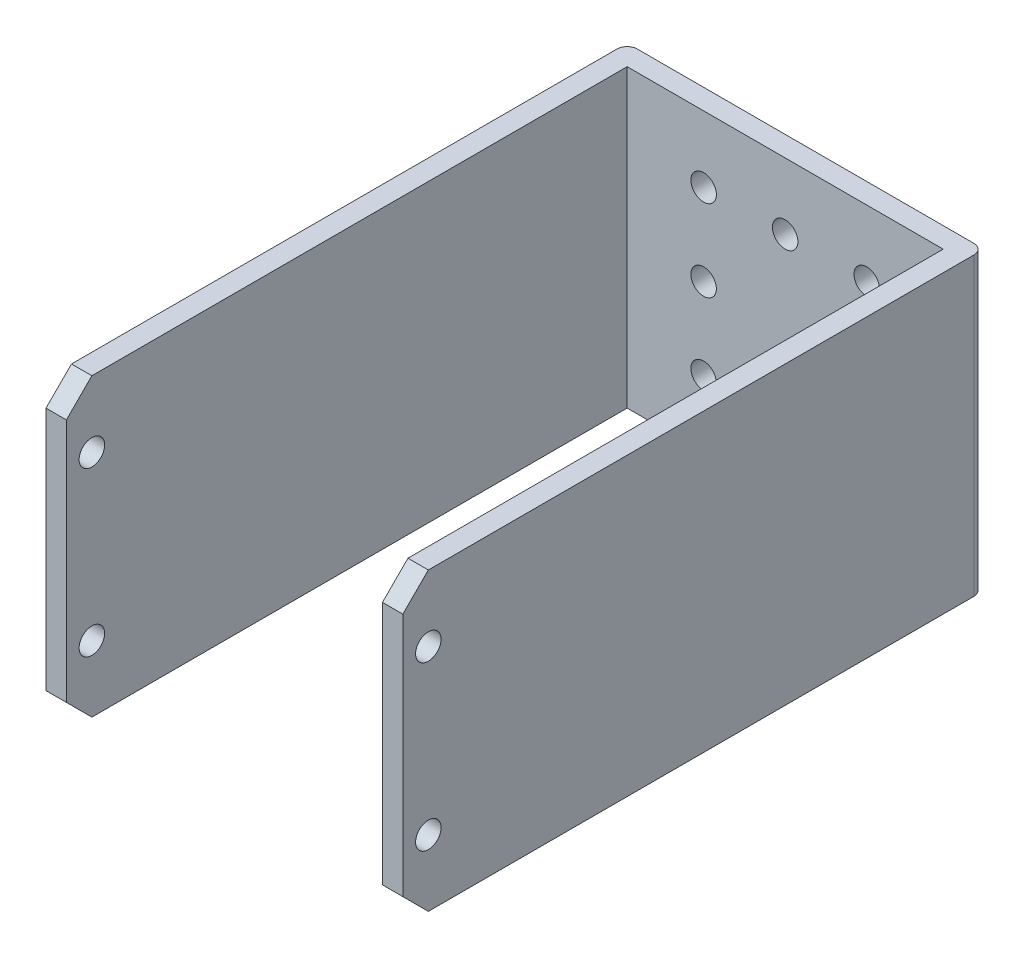
from build123d import *

# Parameters (mm, degrees)
SKETCH1_W           = 35
SKETCH1_H           = 29
BOSS_EXTRUDE1_DEPTH = 57
SKETCH3_W           = 31
SKETCH3_H           = 29
CUT_EXTRUDE1_DEPTH  = 55
FILLET1_R           = 1
CHAMFER1_SIZE       = 2.5
SKETCH4_R           = 1.25
CUT_EXTRUDE2_DEPTH  = 40.5
SKETCH7_R           = 1.25
CUT_EXTRUDE3_DEPTH  = 5


with BuildPart() as part:
    # Sketch1 → Boss-Extrude1 (new body)
    with BuildSketch(Plane.XY):
        with Locations((17.5, 14.5)):
            Rectangle(SKETCH1_W, SKETCH1_H)
    extrude(amount=BOSS_EXTRUDE1_DEPTH)

    # Sketch3 → Cut-Extrude1 (cut)
    with BuildSketch(Plane.XY.offset(57)):
        with Locations((17.5, 14.5)):
            Rectangle(SKETCH3_W, SKETCH3_H)
    extrude(amount=-CUT_EXTRUDE1_DEPTH, mode=Mode.SUBTRACT)

    # Fillet1
    fillet1_edges = [part.edges().sort_by_distance(p)[0] for p in [
        (0, 14.5, 0),
        (35, 14.5, 0),
    ]]
    fillet(fillet1_edges, radius=FILLET1_R)

    # Chamfer1
    chamfer1_edges = [part.edges().sort_by_distance(p)[0] for p in [
        (1, 0, 57),
        (1, 29, 57),
        (34, 0, 57),
        (34, 29, 57),
    ]]
    chamfer(chamfer1_edges, length=CHAMFER1_SIZE)

    # Sketch4 → Cut-Extrude2 (cut)
    with BuildSketch(Plane.ZY):
        with Locations((54.5, 22.5)):
            Circle(SKETCH4_R)
        with Locations((54.5, 6.5)):
            Circle(SKETCH4_R)
    extrude(amount=-CUT_EXTRUDE2_DEPTH, mode=Mode.SUBTRACT)

    # Sketch7 → Cut-Extrude3 (cut)
    with BuildSketch(Plane.XY.offset(2)):
        with Locations((9.5, 6.5)):
            Circle(SKETCH7_R)
        with Locations((17.5, 6.5)):
            Circle(SKETCH7_R)
        with Locations((25.5, 6.5)):
            Circle(SKETCH7_R)
        with Locations((25.5, 14.5)):
            Circle(SKETCH7_R)
        with Locations((17.5, 22.5)):
            Circle(SKETCH7_R)
        with Locations((25.5, 22.5)):
            Circle(SKETCH7_R)
        with Locations((9.5, 14.5)):
            Circle(SKETCH7_R)
        with Locations((9.5, 22.5)):
            Circle(SKETCH7_R)
    extrude(amount=-CUT_EXTRUDE3_DEPTH, mode=Mode.SUBTRACT)


solid = part.part
